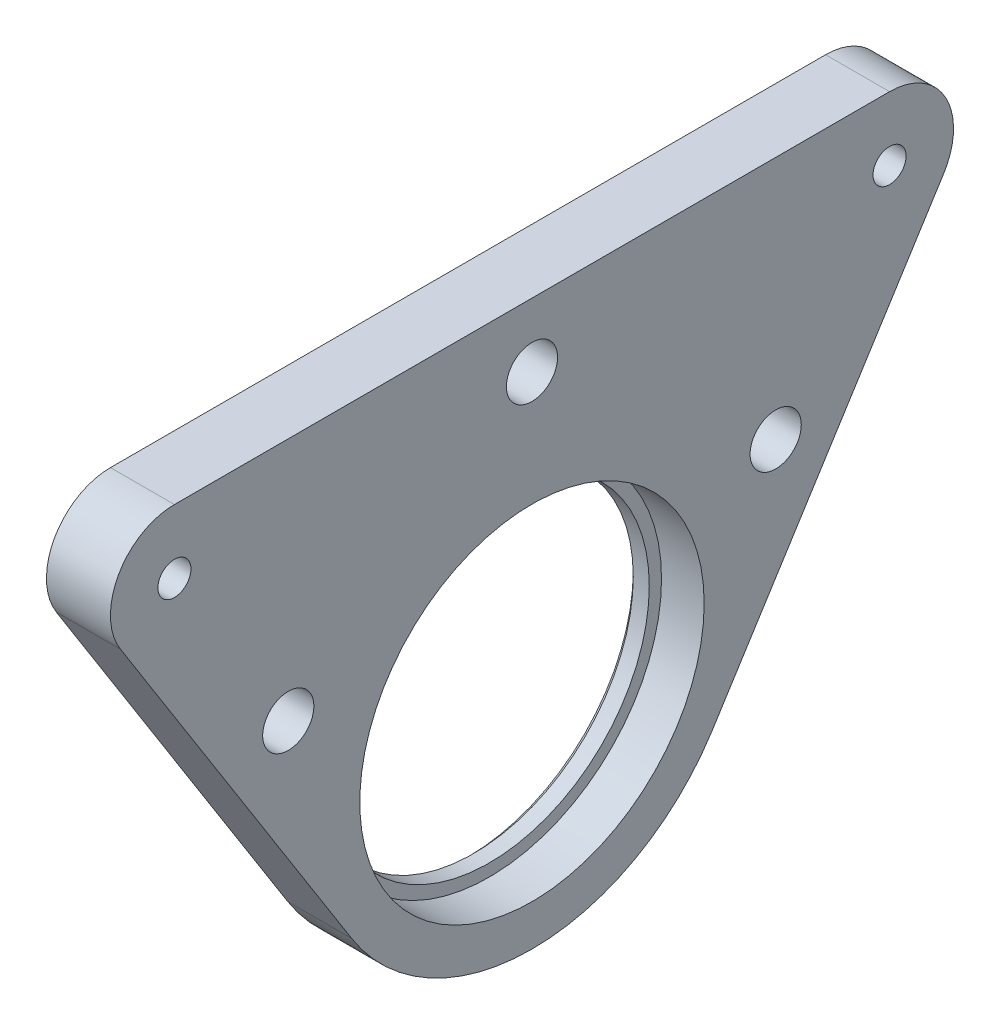
from build123d import *

# Parameters (mm, degrees)
SKETCH1_R           = 20
SKETCH1_R_2         = 15
BOSS_EXTRUDE1_DEPTH = 2
SKETCH2_R           = 20
SKETCH2_R_2         = 16
BOSS_EXTRUDE2_DEPTH = 4
SKETCH3_R           = 2
BOSS_EXTRUDE3_DEPTH = 6
SKETCH4_R           = 2.4
CUT_EXTRUDE1_DEPTH  = 6
SKETCH5_R           = 2
SKETCH5_R_2         = 1.55
BOSS_EXTRUDE4_DEPTH = 6
SKETCH6_R           = 16.15
SKETCH6_R_2         = 16
CUT_EXTRUDE2_DEPTH  = 4
CHAMFER1_SIZE       = 0.5


with BuildPart() as part:
    # Sketch1 → Boss-Extrude1 (new body)
    with BuildSketch(Plane(origin=(0, 0, 0), x_dir=(0, 0, -1), z_dir=(1, 0, 0))):
        Circle(SKETCH1_R)
        Circle(SKETCH1_R_2, mode=Mode.SUBTRACT)
    extrude(amount=BOSS_EXTRUDE1_DEPTH)

    # Sketch2 → Boss-Extrude2 (add)
    with BuildSketch(Plane(origin=(2, 0, 0), x_dir=(0, 0, -1), z_dir=(1, 0, 0))):
        Circle(SKETCH2_R)
        Circle(SKETCH2_R_2, mode=Mode.SUBTRACT)
    extrude(amount=BOSS_EXTRUDE2_DEPTH)

    # Sketch3 → Boss-Extrude3 (add)
    with BuildSketch(Plane(origin=(6, 0, 0), x_dir=(0, 0, -1), z_dir=(1, 0, 0))):
        with BuildLine():
            Line((-38.608830959, 23.677807584), (-16.909895057, -10.679674581))
            ThreePointArc((-16.909895057, -10.679674581), (0, 20), (16.909895057, -10.679674581))
            Line((16.909895057, -10.679674581), (38.608830959, 23.677807584))
            ThreePointArc((38.608830959, 23.677807584), (38.790546744, 29.777964933), (33.535862442, 32.881709959))
            Line((33.535862442, 32.881709959), (-33.535862442, 32.881709959))
            ThreePointArc((-33.535862442, 32.881709959), (-38.790546744, 29.777964933), (-38.608830959, 23.677807584))
        make_face()
        with Locations((-33.535862442, 26.881709959)):
            Circle(SKETCH3_R, mode=Mode.SUBTRACT)
        with Locations((33.535862442, 26.881709959)):
            Circle(SKETCH3_R, mode=Mode.SUBTRACT)
    extrude(amount=-BOSS_EXTRUDE3_DEPTH)

    # Sketch4 → Cut-Extrude1 (cut)
    with BuildSketch(Plane(origin=(6, 0, 0), x_dir=(0, 0, -1), z_dir=(1, 0, 0))):
        with Locations((-22.856187861, 9.971814902)):
            Circle(SKETCH4_R)
        with Locations((22.856187861, 9.971814902)):
            Circle(SKETCH4_R)
        with Locations((0, 26.881709959)):
            Circle(SKETCH4_R)
    extrude(amount=-CUT_EXTRUDE1_DEPTH, mode=Mode.SUBTRACT)

    # Sketch5 → Boss-Extrude4 (add)
    with BuildSketch(Plane(origin=(0, 0, 0), x_dir=(0, 0, -1), z_dir=(1, 0, 0))):
        with Locations((33.535862442, 26.881709959)):
            Circle(SKETCH5_R)
        with Locations((33.535862442, 26.881709959)):
            Circle(SKETCH5_R_2, mode=Mode.SUBTRACT)
        with Locations((-33.535862442, 26.881709959)):
            Circle(SKETCH5_R)
        with Locations((-33.535862442, 26.881709959)):
            Circle(SKETCH5_R_2, mode=Mode.SUBTRACT)
    extrude(amount=BOSS_EXTRUDE4_DEPTH)

    # Sketch6 → Cut-Extrude2 (cut)
    with BuildSketch(Plane(origin=(6, 0, 0), x_dir=(0, 0, -1), z_dir=(1, 0, 0))):
        Circle(SKETCH6_R)
        Circle(SKETCH6_R_2, mode=Mode.SUBTRACT)
    extrude(amount=-CUT_EXTRUDE2_DEPTH, mode=Mode.SUBTRACT)

    # Chamfer1
    chamfer1_edges = [part.edges().sort_by_distance(p)[0] for p in [
        (0, 0, 15),
    ]]
    chamfer(chamfer1_edges, length=CHAMFER1_SIZE)


solid = part.part
